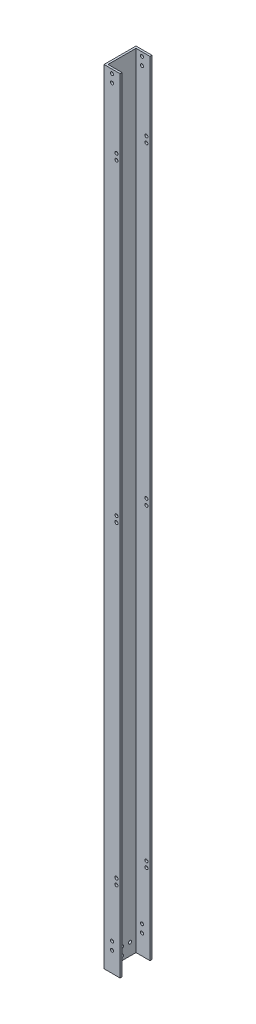
from build123d import *

# Parameters (mm, degrees)
SKETCH1_W               = 25.4
SKETCH1_H               = 50.8
SKETCH1_W_2             = 19.05
SKETCH1_H_2             = 44.45
EXTRUDE_THIN1_DEPTH     = 1244.6
SKETCH5_W               = 3.175
SKETCH5_H               = 44.45
CUT_EXTRUDE2_DEPTH      = 1245.6
SKETCH8_R               = 2.4892
CUT_EXTRUDE4_DEPTH      = 26.4
SKETCH9_R               = 2.4892
CUT_EXTRUDE5_DEPTH      = 51.8
SKETCH6_R               = 2.4892
CUT_EXTRUDE6_DEPTH      = 1
CUT_EXTRUDE6_DEPTH_BACK = 51.8
SKETCH10_R              = 2.4892
CUT_EXTRUDE7_DEPTH      = 51.8


with BuildPart() as part:
    # Sketch1 → Extrude-Thin1 (new body)
    with BuildSketch(Plane(origin=(0, 0, 0), x_dir=(1, 0, 0), z_dir=(0, 1, 0))):
        with Locations((12.7, 25.4)):
            Rectangle(SKETCH1_W, SKETCH1_H)
        with Locations((12.7, 25.4)):
            Rectangle(SKETCH1_W_2, SKETCH1_H_2, mode=Mode.SUBTRACT)
    extrude(amount=EXTRUDE_THIN1_DEPTH)

    # Sketch5 → Cut-Extrude2 (cut, through all)
    with BuildSketch(Plane(origin=(0, 1244.6, 0), x_dir=(1, 0, 0), z_dir=(0, 1, 0))):
        with Locations((23.8125, 25.4)):
            Rectangle(SKETCH5_W, SKETCH5_H)
    extrude(amount=-CUT_EXTRUDE2_DEPTH, mode=Mode.SUBTRACT)

    # Sketch8 → Cut-Extrude4 (cut, through all)
    with BuildSketch(Plane.ZY):
        with Locations((-25.4, 19.05)):
            Circle(SKETCH8_R)
        with Locations((-25.4, 6.35)):
            Circle(SKETCH8_R)
        with Locations((-38.1, 19.05)):
            Circle(SKETCH8_R)
        with Locations((-12.7, 19.05)):
            Circle(SKETCH8_R)
    extrude(amount=-CUT_EXTRUDE4_DEPTH, mode=Mode.SUBTRACT)

    # Sketch9 → Cut-Extrude5 (cut, through all)
    with BuildSketch(Plane.XY):
        with Locations((12.7, 44.45)):
            Circle(SKETCH9_R)
        with Locations((12.7, 31.75)):
            Circle(SKETCH9_R)
        with Locations((12.7, 1238.25)):
            Circle(SKETCH9_R)
        with Locations((12.7, 1225.55)):
            Circle(SKETCH9_R)
    extrude(amount=-CUT_EXTRUDE5_DEPTH, mode=Mode.SUBTRACT)

    # Sketch6 → Cut-Extrude6 (cut, two sides)
    with BuildSketch(Plane.XY) as cut_extrude6_sk:
        with Locations((19.685, 1132.205)):
            Circle(SKETCH6_R)
        with Locations((19.685, 134.62)):
            Circle(SKETCH6_R)
        with Locations((19.685, 125.095)):
            Circle(SKETCH6_R)
        with Locations((19.685, 1122.68)):
            Circle(SKETCH6_R)
    extrude(amount=CUT_EXTRUDE6_DEPTH, mode=Mode.SUBTRACT)
    extrude(cut_extrude6_sk.sketch, amount=-CUT_EXTRUDE6_DEPTH_BACK, mode=Mode.SUBTRACT)

    # Sketch10 → Cut-Extrude7 (cut, through all)
    with BuildSketch(Plane(origin=(0, 0, -50.8), x_dir=(-1, 0, 0), z_dir=(0, 0, -1))):
        with Locations((-19.685, 633.4125)):
            Circle(SKETCH10_R)
        with Locations((-19.685, 623.8875)):
            Circle(SKETCH10_R)
    extrude(amount=-CUT_EXTRUDE7_DEPTH, mode=Mode.SUBTRACT)


solid = part.part
